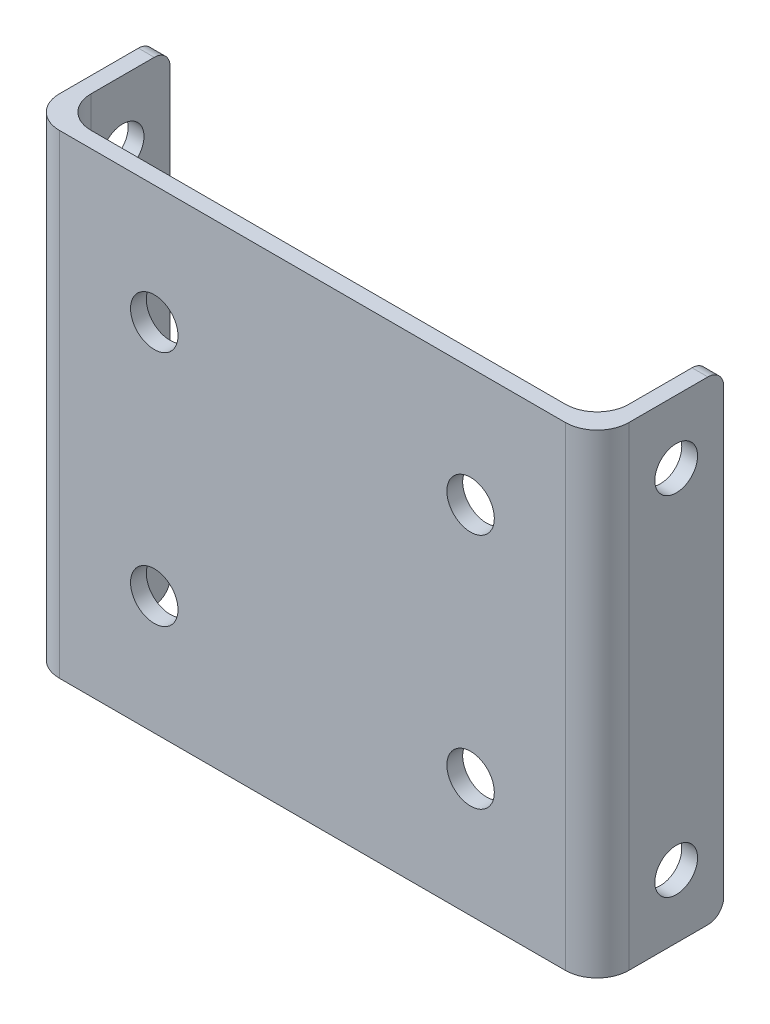
from build123d import *

# Parameters (mm, degrees)
BOSS_EXTRUDE1_DEPTH = 30
FILLET2_R           = 2
SKETCH3_R           = 1.5
CUT_EXTRUDE4_DEPTH  = 9
SKETCH4_R           = 1.35
CUT_EXTRUDE3_DEPTH  = 37
FILLET3_R           = 1


with BuildPart() as part:
    # Sketch1 → Boss-Extrude1 (new body)
    with BuildSketch(Plane(origin=(0, 0, 0), x_dir=(1, 0, 0), z_dir=(0, 1, 0))):
        Polygon((-21.5, 0.5), (12.5, 0.5), (12.5, 7.5), (13.5, 7.5), (13.5, 0.5), (13.5, -0.5), (-22.5, -0.5), (-22.5, 0.5), (-22.5, 7.5), (-21.5, 7.5), align=None)
    extrude(amount=BOSS_EXTRUDE1_DEPTH)

    # Fillet2
    fillet2_edges = [part.edges().sort_by_distance(p)[0] for p in [
        (13.5, 15, 0.5),
        (-22.5, 15, 0.5),
        (-21.5, 15, -0.5),
        (12.5, 15, -0.5),
    ]]
    fillet(fillet2_edges, radius=FILLET2_R)

    # Sketch3 → Cut-Extrude4 (cut, through all)
    with BuildSketch(Plane.XY.offset(0.5)):
        with Locations((-14.5, 22.5)):
            Circle(SKETCH3_R)
        with Locations((5.5, 22.5)):
            Circle(SKETCH3_R)
        with Locations((-14.5, 7.5)):
            Circle(SKETCH3_R)
        with Locations((5.5, 7.5)):
            Circle(SKETCH3_R)
    extrude(amount=-CUT_EXTRUDE4_DEPTH, mode=Mode.SUBTRACT)

    # Sketch4 → Cut-Extrude3 (cut, through all)
    with BuildSketch(Plane(origin=(13.5, 0, 0), x_dir=(0, 0, -1), z_dir=(1, 0, 0))):
        with Locations((4.5, 26)):
            Circle(SKETCH4_R)
        with Locations((4.5, 4)):
            Circle(SKETCH4_R)
    extrude(amount=-CUT_EXTRUDE3_DEPTH, mode=Mode.SUBTRACT)

    # Fillet3
    fillet3_edges = [part.edges().sort_by_distance(p)[0] for p in [
        (13, 30, -7.5),
        (-22, 0, -7.5),
        (13, 0, -7.5),
        (-22, 30, -7.5),
    ]]
    fillet(fillet3_edges, radius=FILLET3_R)


solid = part.part
